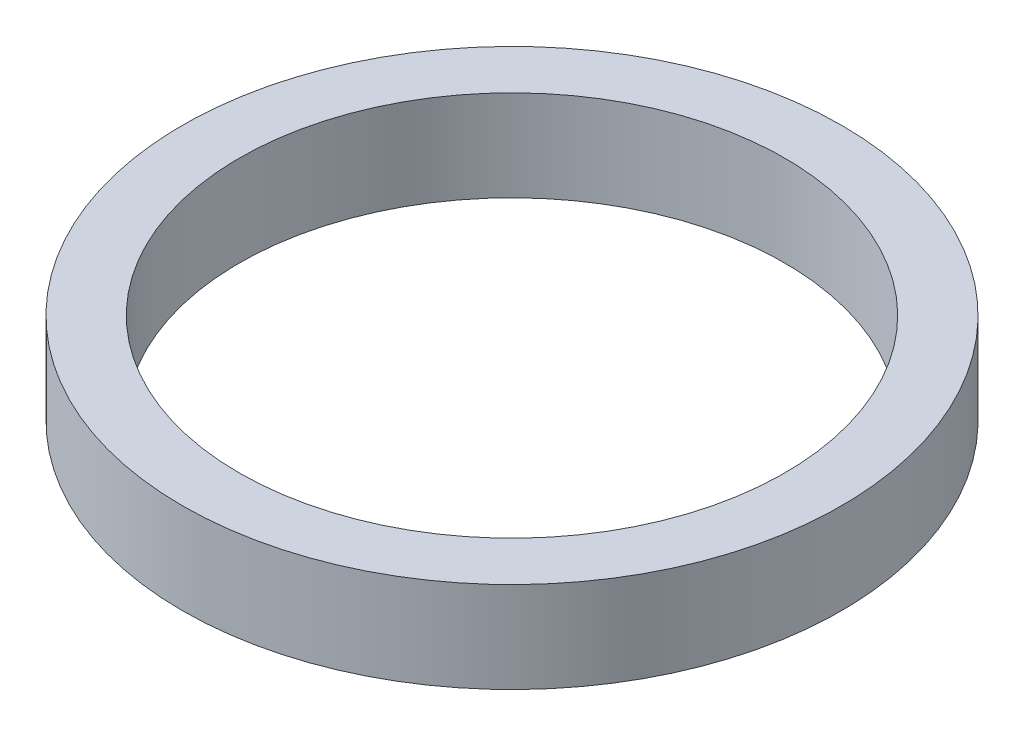
from build123d import *

# Parameters (mm, degrees)
SKETCH1_R           = 3.625
SKETCH1_R_2         = 3
BOSS_EXTRUDE1_DEPTH = 1


with BuildPart() as part:
    # Sketch1 → Boss-Extrude1 (new body)
    with BuildSketch(Plane(origin=(0, 0, 0), x_dir=(1, 0, 0), z_dir=(0, 1, 0))):
        Circle(SKETCH1_R)
        Circle(SKETCH1_R_2, mode=Mode.SUBTRACT)
    extrude(amount=BOSS_EXTRUDE1_DEPTH)


solid = part.part
